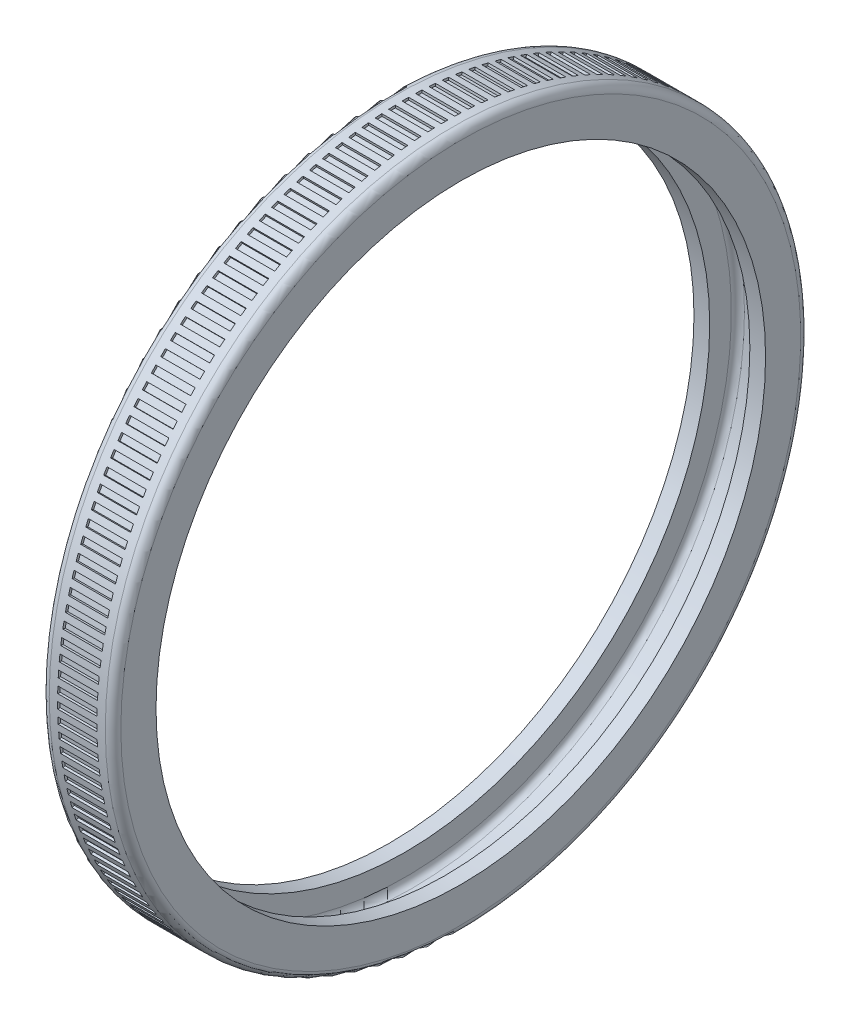
from build123d import *

# Parameters (mm, degrees)
SKETCH2_W          = 0.8
SKETCH2_H          = 2
CUT_EXTRUDE1_DEPTH = 2.4
CIRPATTERN1_COUNT  = 163


with BuildPart() as part:
    # Sketch1 → Revolve1 (revolve)
    with BuildSketch(Plane.XY):
        with BuildLine():
            Line((-4.375, 37.25), (-4.375, 41.55))
            ThreePointArc((-4.375, 41.55), (-4.096751442, 42.221751442), (-3.425, 42.5))
            Line((-3.425, 42.5), (3.425, 42.5))
            ThreePointArc((3.425, 42.5), (4.096751442, 42.221751442), (4.375, 41.55))
            Line((4.375, 41.55), (4.375, 37.25))
            Line((4.375, 37.25), (2.454347753, 37.25))
            Line((2.454347753, 37.25), (2.454347753, 39.9))
            ThreePointArc((2.454347753, 39.9), (2.220033178, 40.465685425), (1.654347753, 40.7))
            Line((1.654347753, 40.7), (-1.654347753, 40.7))
            ThreePointArc((-1.654347753, 40.7), (-2.220033178, 40.465685425), (-2.454347753, 39.9))
            Line((-2.454347753, 39.9), (-2.454347753, 37.25))
            Line((-2.454347753, 37.25), (-4.375, 37.25))
        make_face()
    revolve(axis=Axis((-1000, 0, 0), (1, 0, 0)))

    # Sketch2 → Cut-Extrude1 (cut, symmetric)
    with BuildSketch(Plane(origin=(0, 0, 0), x_dir=(0, 0, -1), z_dir=(1, 0, 0))):
        with Locations((0, 43.2)):
            Rectangle(SKETCH2_W, SKETCH2_H)
    cut_extrude1 = extrude(amount=CUT_EXTRUDE1_DEPTH, both=True, mode=Mode.SUBTRACT)

    # CirPattern1: Cut-Extrude1 ×163 about axis
    cirpattern1_axis = Axis((0, 0, 0), (1, 0, 0))
    for i in range(1, CIRPATTERN1_COUNT):
        add(cut_extrude1.rotate(cirpattern1_axis, i * 360 / CIRPATTERN1_COUNT), mode=Mode.SUBTRACT)


solid = part.part
